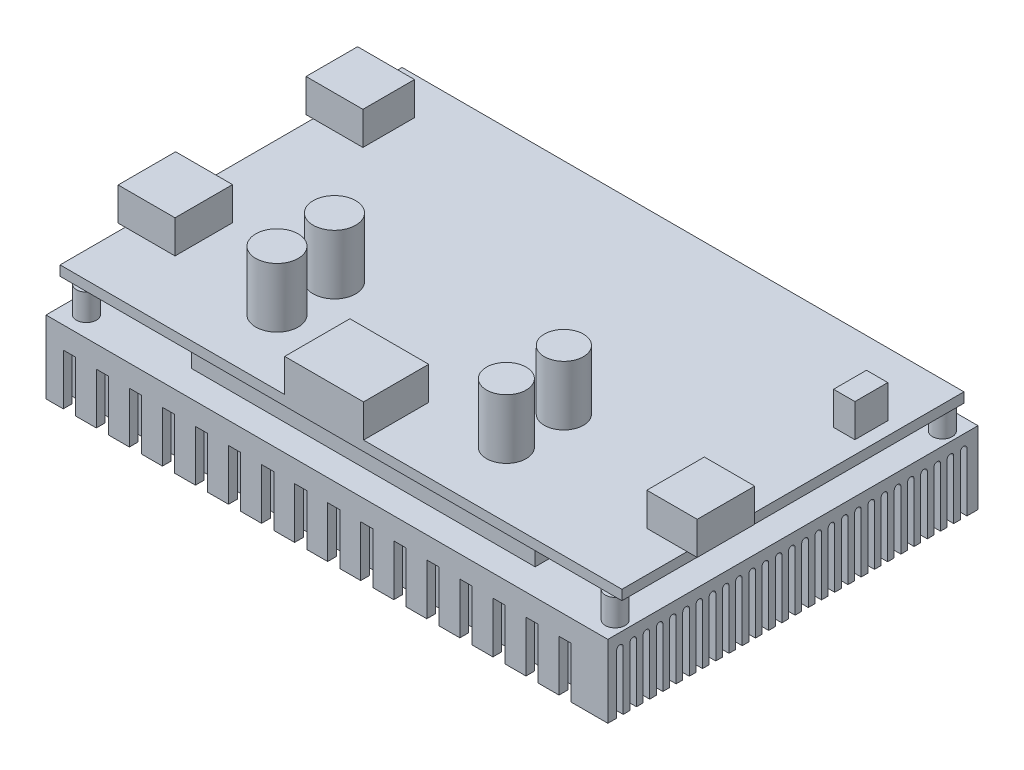
from build123d import *

# Parameters (mm, degrees)
SKETCH_1_W          = 85
SKETCH_1_H          = 56
EXTRUDE_1_DEPTH     = 11
SKETCH_2_R          = 1.5
SKETCH_2_W          = 52
SKETCH_2_H          = 35
EXTRUDE_2_DEPTH     = 4
SKETCH_3_W          = 85
SKETCH_3_H          = 51.741502326
EXTRUDE_3_DEPTH     = 1.5
SKETCH_4_R          = 3.21950927
SKETCH_4_R_2        = 3.214510029
SKETCH_4_R_3        = 2.959219371
SKETCH_4_R_4        = 3
SKETCH_4_W          = 8.608638168
SKETCH_4_H          = 7.80157834
SKETCH_4_H_2        = 8.698311483
SKETCH_4_W_2        = 3.228239314
SKETCH_4_H_3        = 4.976868941
SKETCH_4_W_3        = 7.622231712
SKETCH_4_W_4        = 11.926550797
SKETCH_4_H_4        = 9.864064568
EXTRUDE_4_DEPTH     = 5
SKETCH_5_R          = 3
SKETCH_5_R_2        = 2.959219371
SKETCH_5_R_3        = 3.214510029
SKETCH_5_R_4        = 3.21950927
EXTRUDE_5_DEPTH     = 4
SKETCH_6_W          = 4.962626709
SKETCH_6_H          = 3.072102248
SKETCH_6_W_2        = 5.671573382
CUT_EXTRUDE_1_DEPTH = 4
CUT_EXTRUDE_2_DEPTH = 87.081230729
SKETCH_8_W          = 1.848553721
SKETCH_8_H          = 7.71269111
CUT_EXTRUDE_3_DEPTH = 57


with BuildPart() as part:
    # 草图1 → 凸台-拉伸1 (new body)
    with BuildSketch(Plane(origin=(0, 0, 0), x_dir=(1, 0, 0), z_dir=(0, 1, 0))):
        Rectangle(SKETCH_1_W, SKETCH_1_H)
    extrude(amount=EXTRUDE_1_DEPTH)

    # 草图2 → 凸台-拉伸2 (add)
    with BuildSketch(Plane(origin=(0, 11, 0), x_dir=(1, 0, 0), z_dir=(0, 1, 0))):
        with Locations((-39.5, 24.615324764)):
            Circle(SKETCH_2_R)
        with Locations((40.5, 24.615324764)):
            Circle(SKETCH_2_R)
        with Locations((40.5, -24.884344707)):
            Circle(SKETCH_2_R)
        with Locations((-39.5, -24.884344707)):
            Circle(SKETCH_2_R)
        with Locations((1.5, -6.5)):
            Rectangle(SKETCH_2_W, SKETCH_2_H)
    extrude(amount=EXTRUDE_2_DEPTH)

    # 草图3 → 凸台-拉伸3 (add)
    with BuildSketch(Plane(origin=(0, 15, 0), x_dir=(1, 0, 0), z_dir=(0, 1, 0))):
        Rectangle(SKETCH_3_W, SKETCH_3_H)
    extrude(amount=EXTRUDE_3_DEPTH)

    # 草图4 → 凸台-拉伸4 (add)
    with BuildSketch(Plane(origin=(0, 16.5, 0), x_dir=(1, 0, 0), z_dir=(0, 1, 0))):
        with Locations((-19.548782508, -7.308375112)):
            Circle(SKETCH_4_R)
        with Locations((-19.548782508, -16.006686595)):
            Circle(SKETCH_4_R_2)
        with Locations((15.15479011, -7.308375112)):
            Circle(SKETCH_4_R_3)
        with Locations((15.15479011, -16.006686595)):
            Circle(SKETCH_4_R_4)
        with Locations((-39.276911645, 16.320543195)):
            Rectangle(SKETCH_4_W, SKETCH_4_H)
        with Locations((-39.276911645, -11.657530854)):
            Rectangle(SKETCH_4_W, SKETCH_4_H_2)
        with Locations((38.918218388, 13.832108725)):
            Rectangle(SKETCH_4_W_2, SKETCH_4_H_3)
        with Locations((40.218481445, -11.657530854)):
            Rectangle(SKETCH_4_W_3, SKETCH_4_H_2)
        with Locations((-2.555689456, -20.938718879)):
            Rectangle(SKETCH_4_W_4, SKETCH_4_H_4)
    extrude(amount=EXTRUDE_4_DEPTH)

    # 草图5 → 凸台-拉伸5 (add)
    with BuildSketch(Plane(origin=(0, 21.5, 0), x_dir=(1, 0, 0), z_dir=(0, 1, 0))):
        with Locations((15.15479011, -16.006686595)):
            Circle(SKETCH_5_R)
        with Locations((15.15479011, -7.308375112)):
            Circle(SKETCH_5_R_2)
        with Locations((-19.548782508, -16.006686595)):
            Circle(SKETCH_5_R_3)
        with Locations((-19.548782508, -7.308375112)):
            Circle(SKETCH_5_R_4)
    extrude(amount=EXTRUDE_5_DEPTH)

    # 草图6 → 切除-拉伸1 (cut)
    with BuildSketch(Plane.ZY.offset(43.581230729)):
        with Locations((-16.246694584, 18.805586163)):
            Rectangle(SKETCH_6_W, SKETCH_6_H)
        with Locations((11.402225653, 18.805586163)):
            Rectangle(SKETCH_6_W_2, SKETCH_6_H)
    extrude(amount=-CUT_EXTRUDE_1_DEPTH, mode=Mode.SUBTRACT)

    # 草图7 → 切除-拉伸2 (cut, through all)
    with BuildSketch(Plane(origin=(42.5, 0, 0), x_dir=(0, 0, -1), z_dir=(1, 0, 0))):
        with BuildLine():
            Line((-25.671948001, 8.880332745), (-25.671948001, -2.580971798))
            ThreePointArc((-25.671948001, -2.580971798), (-26.171948001, -3.080971798), (-26.671948001, -2.580971798))
            Line((-26.671948001, -2.580971798), (-26.671948001, 8.880332745))
            ThreePointArc((-26.671948001, 8.880332745), (-26.171948001, 9.380332745), (-25.671948001, 8.880332745))
        make_face()
        with BuildLine():
            Line((-23.671948001, 8.880332745), (-23.671948001, -2.580971798))
            ThreePointArc((-23.671948001, -2.580971798), (-24.171948001, -3.080971798), (-24.671948001, -2.580971798))
            Line((-24.671948001, -2.580971798), (-24.671948001, 8.880332745))
            ThreePointArc((-24.671948001, 8.880332745), (-24.171948001, 9.380332745), (-23.671948001, 8.880332745))
        make_face()
        with BuildLine():
            Line((-21.671948001, 8.880332745), (-21.671948001, -2.580971798))
            ThreePointArc((-21.671948001, -2.580971798), (-22.171948001, -3.080971798), (-22.671948001, -2.580971798))
            Line((-22.671948001, -2.580971798), (-22.671948001, 8.880332745))
            ThreePointArc((-22.671948001, 8.880332745), (-22.171948001, 9.380332745), (-21.671948001, 8.880332745))
        make_face()
        with BuildLine():
            Line((-19.671948001, 8.880332745), (-19.671948001, -2.580971798))
            ThreePointArc((-19.671948001, -2.580971798), (-20.171948001, -3.080971798), (-20.671948001, -2.580971798))
            Line((-20.671948001, -2.580971798), (-20.671948001, 8.880332745))
            ThreePointArc((-20.671948001, 8.880332745), (-20.171948001, 9.380332745), (-19.671948001, 8.880332745))
        make_face()
        with BuildLine():
            Line((-17.671948001, 8.880332745), (-17.671948001, -2.580971798))
            ThreePointArc((-17.671948001, -2.580971798), (-18.171948001, -3.080971798), (-18.671948001, -2.580971798))
            Line((-18.671948001, -2.580971798), (-18.671948001, 8.880332745))
            ThreePointArc((-18.671948001, 8.880332745), (-18.171948001, 9.380332745), (-17.671948001, 8.880332745))
        make_face()
        with BuildLine():
            Line((-15.671948001, 8.880332745), (-15.671948001, -2.580971798))
            ThreePointArc((-15.671948001, -2.580971798), (-16.171948001, -3.080971798), (-16.671948001, -2.580971798))
            Line((-16.671948001, -2.580971798), (-16.671948001, 8.880332745))
            ThreePointArc((-16.671948001, 8.880332745), (-16.171948001, 9.380332745), (-15.671948001, 8.880332745))
        make_face()
        with BuildLine():
            Line((-13.671948001, 8.880332745), (-13.671948001, -2.580971798))
            ThreePointArc((-13.671948001, -2.580971798), (-14.171948001, -3.080971798), (-14.671948001, -2.580971798))
            Line((-14.671948001, -2.580971798), (-14.671948001, 8.880332745))
            ThreePointArc((-14.671948001, 8.880332745), (-14.171948001, 9.380332745), (-13.671948001, 8.880332745))
        make_face()
        with BuildLine():
            Line((-11.671948001, 8.880332745), (-11.671948001, -2.580971798))
            ThreePointArc((-11.671948001, -2.580971798), (-12.171948001, -3.080971798), (-12.671948001, -2.580971798))
            Line((-12.671948001, -2.580971798), (-12.671948001, 8.880332745))
            ThreePointArc((-12.671948001, 8.880332745), (-12.171948001, 9.380332745), (-11.671948001, 8.880332745))
        make_face()
        with BuildLine():
            Line((-9.671948001, 8.880332745), (-9.671948001, -2.580971798))
            ThreePointArc((-9.671948001, -2.580971798), (-10.171948001, -3.080971798), (-10.671948001, -2.580971798))
            Line((-10.671948001, -2.580971798), (-10.671948001, 8.880332745))
            ThreePointArc((-10.671948001, 8.880332745), (-10.171948001, 9.380332745), (-9.671948001, 8.880332745))
        make_face()
        with BuildLine():
            Line((-7.671948001, 8.880332745), (-7.671948001, -2.580971798))
            ThreePointArc((-7.671948001, -2.580971798), (-8.171948001, -3.080971798), (-8.671948001, -2.580971798))
            Line((-8.671948001, -2.580971798), (-8.671948001, 8.880332745))
            ThreePointArc((-8.671948001, 8.880332745), (-8.171948001, 9.380332745), (-7.671948001, 8.880332745))
        make_face()
        with BuildLine():
            Line((-5.671948001, 8.880332745), (-5.671948001, -2.580971798))
            ThreePointArc((-5.671948001, -2.580971798), (-6.171948001, -3.080971798), (-6.671948001, -2.580971798))
            Line((-6.671948001, -2.580971798), (-6.671948001, 8.880332745))
            ThreePointArc((-6.671948001, 8.880332745), (-6.171948001, 9.380332745), (-5.671948001, 8.880332745))
        make_face()
        with BuildLine():
            Line((-3.671948001, 8.880332745), (-3.671948001, -2.580971798))
            ThreePointArc((-3.671948001, -2.580971798), (-4.171948001, -3.080971798), (-4.671948001, -2.580971798))
            Line((-4.671948001, -2.580971798), (-4.671948001, 8.880332745))
            ThreePointArc((-4.671948001, 8.880332745), (-4.171948001, 9.380332745), (-3.671948001, 8.880332745))
        make_face()
        with BuildLine():
            Line((-1.671948001, 8.880332745), (-1.671948001, -2.580971798))
            ThreePointArc((-1.671948001, -2.580971798), (-2.171948001, -3.080971798), (-2.671948001, -2.580971798))
            Line((-2.671948001, -2.580971798), (-2.671948001, 8.880332745))
            ThreePointArc((-2.671948001, 8.880332745), (-2.171948001, 9.380332745), (-1.671948001, 8.880332745))
        make_face()
        with BuildLine():
            Line((0.328051999, 8.880332745), (0.328051999, -2.580971798))
            ThreePointArc((0.328051999, -2.580971798), (-0.171948001, -3.080971798), (-0.671948001, -2.580971798))
            Line((-0.671948001, -2.580971798), (-0.671948001, 8.880332745))
            ThreePointArc((-0.671948001, 8.880332745), (-0.171948001, 9.380332745), (0.328051999, 8.880332745))
        make_face()
        with BuildLine():
            Line((2.328051999, 8.880332745), (2.328051999, -2.580971798))
            ThreePointArc((2.328051999, -2.580971798), (1.828051999, -3.080971798), (1.328051999, -2.580971798))
            Line((1.328051999, -2.580971798), (1.328051999, 8.880332745))
            ThreePointArc((1.328051999, 8.880332745), (1.828051999, 9.380332745), (2.328051999, 8.880332745))
        make_face()
        with BuildLine():
            Line((4.328051999, 8.880332745), (4.328051999, -2.580971798))
            ThreePointArc((4.328051999, -2.580971798), (3.828051999, -3.080971798), (3.328051999, -2.580971798))
            Line((3.328051999, -2.580971798), (3.328051999, 8.880332745))
            ThreePointArc((3.328051999, 8.880332745), (3.828051999, 9.380332745), (4.328051999, 8.880332745))
        make_face()
        with BuildLine():
            Line((6.328051999, 8.880332745), (6.328051999, -2.580971798))
            ThreePointArc((6.328051999, -2.580971798), (5.828051999, -3.080971798), (5.328051999, -2.580971798))
            Line((5.328051999, -2.580971798), (5.328051999, 8.880332745))
            ThreePointArc((5.328051999, 8.880332745), (5.828051999, 9.380332745), (6.328051999, 8.880332745))
        make_face()
        with BuildLine():
            Line((8.328051999, 8.880332745), (8.328051999, -2.580971798))
            ThreePointArc((8.328051999, -2.580971798), (7.828051999, -3.080971798), (7.328051999, -2.580971798))
            Line((7.328051999, -2.580971798), (7.328051999, 8.880332745))
            ThreePointArc((7.328051999, 8.880332745), (7.828051999, 9.380332745), (8.328051999, 8.880332745))
        make_face()
        with BuildLine():
            Line((10.328051999, 8.880332745), (10.328051999, -2.580971798))
            ThreePointArc((10.328051999, -2.580971798), (9.828051999, -3.080971798), (9.328051999, -2.580971798))
            Line((9.328051999, -2.580971798), (9.328051999, 8.880332745))
            ThreePointArc((9.328051999, 8.880332745), (9.828051999, 9.380332745), (10.328051999, 8.880332745))
        make_face()
        with BuildLine():
            Line((12.328051999, 8.880332745), (12.328051999, -2.580971798))
            ThreePointArc((12.328051999, -2.580971798), (11.828051999, -3.080971798), (11.328051999, -2.580971798))
            Line((11.328051999, -2.580971798), (11.328051999, 8.880332745))
            ThreePointArc((11.328051999, 8.880332745), (11.828051999, 9.380332745), (12.328051999, 8.880332745))
        make_face()
        with BuildLine():
            Line((14.328051999, 8.880332745), (14.328051999, -2.580971798))
            ThreePointArc((14.328051999, -2.580971798), (13.828051999, -3.080971798), (13.328051999, -2.580971798))
            Line((13.328051999, -2.580971798), (13.328051999, 8.880332745))
            ThreePointArc((13.328051999, 8.880332745), (13.828051999, 9.380332745), (14.328051999, 8.880332745))
        make_face()
        with BuildLine():
            Line((16.328051999, 8.880332745), (16.328051999, -2.580971798))
            ThreePointArc((16.328051999, -2.580971798), (15.828051999, -3.080971798), (15.328051999, -2.580971798))
            Line((15.328051999, -2.580971798), (15.328051999, 8.880332745))
            ThreePointArc((15.328051999, 8.880332745), (15.828051999, 9.380332745), (16.328051999, 8.880332745))
        make_face()
        with BuildLine():
            Line((18.328051999, 8.880332745), (18.328051999, -2.580971798))
            ThreePointArc((18.328051999, -2.580971798), (17.828051999, -3.080971798), (17.328051999, -2.580971798))
            Line((17.328051999, -2.580971798), (17.328051999, 8.880332745))
            ThreePointArc((17.328051999, 8.880332745), (17.828051999, 9.380332745), (18.328051999, 8.880332745))
        make_face()
        with BuildLine():
            Line((20.328051999, 8.880332745), (20.328051999, -2.580971798))
            ThreePointArc((20.328051999, -2.580971798), (19.828051999, -3.080971798), (19.328051999, -2.580971798))
            Line((19.328051999, -2.580971798), (19.328051999, 8.880332745))
            ThreePointArc((19.328051999, 8.880332745), (19.828051999, 9.380332745), (20.328051999, 8.880332745))
        make_face()
        with BuildLine():
            Line((22.328051999, 8.880332745), (22.328051999, -2.580971798))
            ThreePointArc((22.328051999, -2.580971798), (21.828051999, -3.080971798), (21.328051999, -2.580971798))
            Line((21.328051999, -2.580971798), (21.328051999, 8.880332745))
            ThreePointArc((21.328051999, 8.880332745), (21.828051999, 9.380332745), (22.328051999, 8.880332745))
        make_face()
        with BuildLine():
            Line((24.328051999, 8.880332745), (24.328051999, -2.580971798))
            ThreePointArc((24.328051999, -2.580971798), (23.828051999, -3.080971798), (23.328051999, -2.580971798))
            Line((23.328051999, -2.580971798), (23.328051999, 8.880332745))
            ThreePointArc((23.328051999, 8.880332745), (23.828051999, 9.380332745), (24.328051999, 8.880332745))
        make_face()
        with BuildLine():
            Line((26.328051999, 8.880332745), (26.328051999, -2.580971798))
            ThreePointArc((26.328051999, -2.580971798), (25.828051999, -3.080971798), (25.328051999, -2.580971798))
            Line((25.328051999, -2.580971798), (25.328051999, 8.880332745))
            ThreePointArc((25.328051999, 8.880332745), (25.828051999, 9.380332745), (26.328051999, 8.880332745))
        make_face()
    extrude(amount=-CUT_EXTRUDE_2_DEPTH, mode=Mode.SUBTRACT)

    # 草图8 → 切除-拉伸3 (cut, through all)
    with BuildSketch(Plane.XY.offset(28)):
        with Locations((-38.965155601, 3.856345555)):
            Rectangle(SKETCH_8_W, SKETCH_8_H)
        with Locations((-33.965155601, 3.856345555)):
            Rectangle(SKETCH_8_W, SKETCH_8_H)
        with Locations((-28.965155601, 3.856345555)):
            Rectangle(SKETCH_8_W, SKETCH_8_H)
        with Locations((-23.965155601, 3.856345555)):
            Rectangle(SKETCH_8_W, SKETCH_8_H)
        with Locations((-18.965155601, 3.856345555)):
            Rectangle(SKETCH_8_W, SKETCH_8_H)
        with Locations((-13.965155601, 3.856345555)):
            Rectangle(SKETCH_8_W, SKETCH_8_H)
        with Locations((-8.965155601, 3.856345555)):
            Rectangle(SKETCH_8_W, SKETCH_8_H)
        with Locations((-3.965155601, 3.856345555)):
            Rectangle(SKETCH_8_W, SKETCH_8_H)
        with Locations((1.0348444, 3.856345555)):
            Rectangle(SKETCH_8_W, SKETCH_8_H)
        with Locations((6.0348444, 3.856345555)):
            Rectangle(SKETCH_8_W, SKETCH_8_H)
        with Locations((11.034844399, 3.856345555)):
            Rectangle(SKETCH_8_W, SKETCH_8_H)
        with Locations((16.0348444, 3.856345555)):
            Rectangle(SKETCH_8_W, SKETCH_8_H)
        with Locations((21.0348444, 3.856345555)):
            Rectangle(SKETCH_8_W, SKETCH_8_H)
        with Locations((26.0348444, 3.856345555)):
            Rectangle(SKETCH_8_W, SKETCH_8_H)
        with Locations((31.0348444, 3.856345555)):
            Rectangle(SKETCH_8_W, SKETCH_8_H)
        with Locations((36.0348444, 3.856345555)):
            Rectangle(SKETCH_8_W, SKETCH_8_H)
    extrude(amount=-CUT_EXTRUDE_3_DEPTH, mode=Mode.SUBTRACT)


solid = part.part
